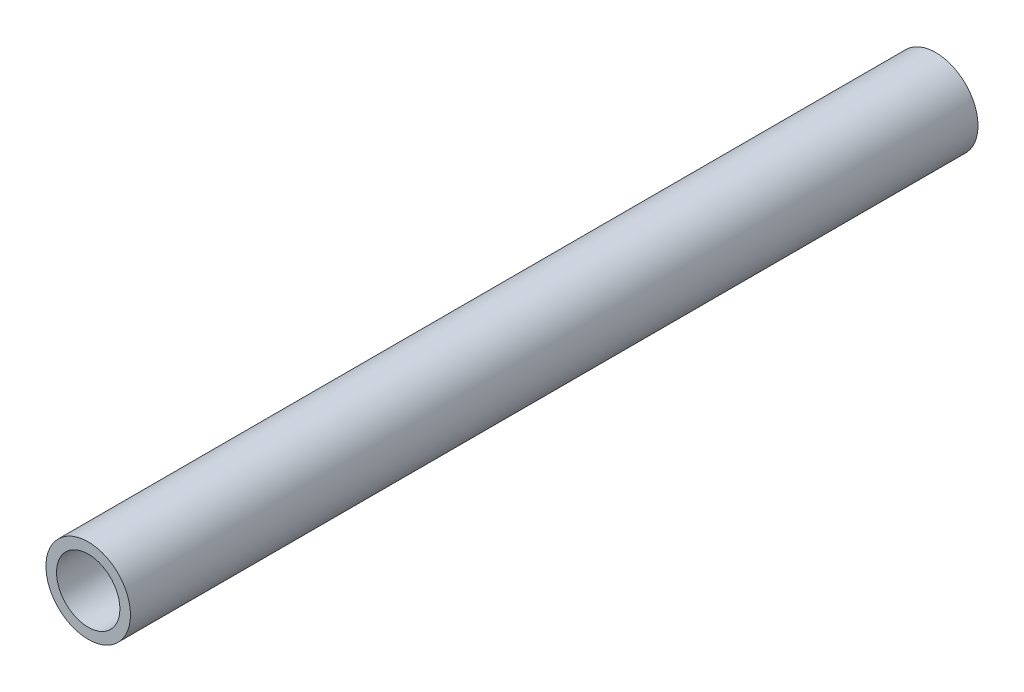
from build123d import *

# Parameters (mm, degrees)
SKETCH2_R           = 50.8
SKETCH2_R_2         = 38.1
EXTRUDE_THIN1_DEPTH = 1018.54


with BuildPart() as part:
    # Sketch2 → Extrude-Thin1 (new body)
    with BuildSketch(Plane.XY):
        Circle(SKETCH2_R)
        Circle(SKETCH2_R_2, mode=Mode.SUBTRACT)
    extrude(amount=EXTRUDE_THIN1_DEPTH)


solid = part.part
